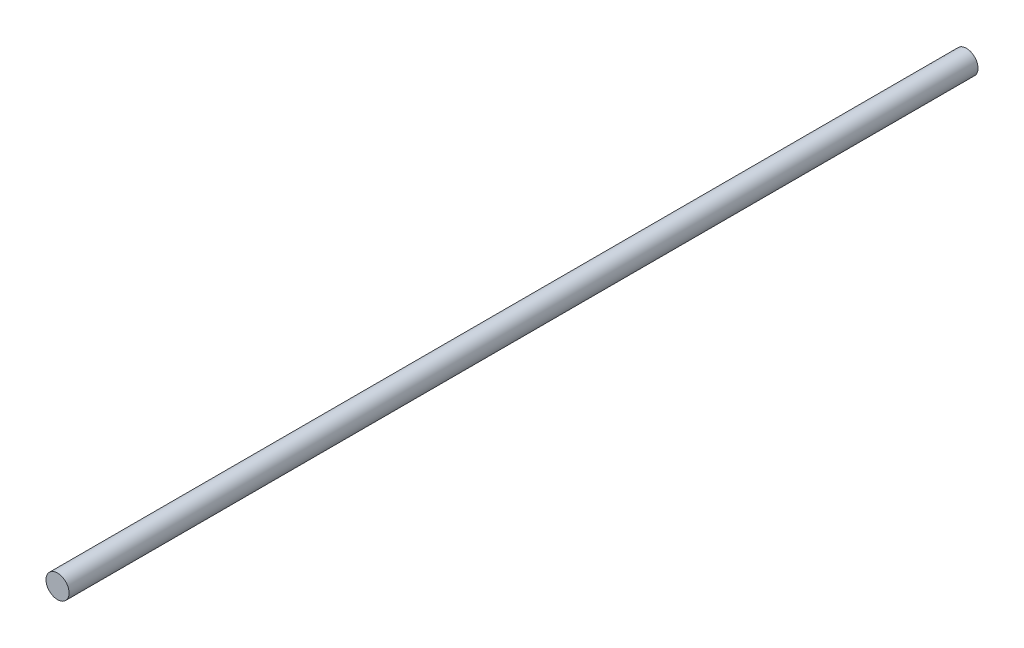
from build123d import *

# Parameters (mm, degrees)
SKETCH1_R           = 4
BOSS_EXTRUDE1_DEPTH = 315


with BuildPart() as part:
    # Sketch1 → Boss-Extrude1 (new body)
    with BuildSketch(Plane.XY):
        Circle(SKETCH1_R)
    extrude(amount=BOSS_EXTRUDE1_DEPTH)


solid = part.part
